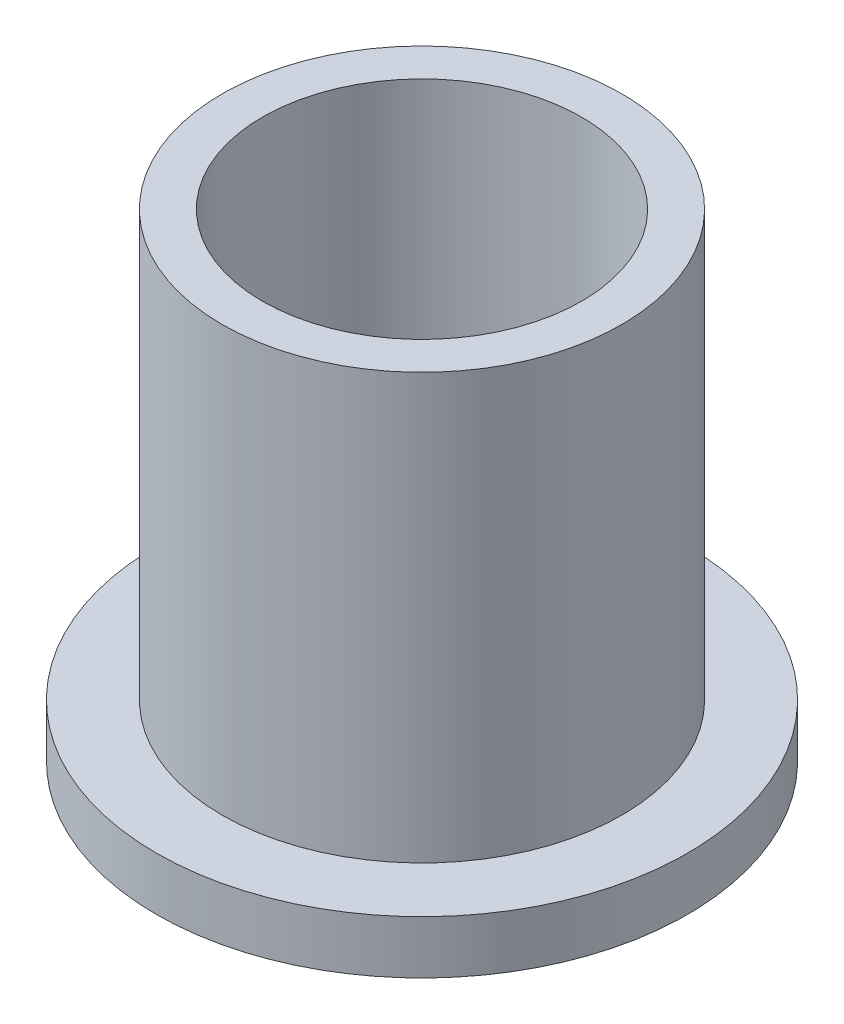
from build123d import *

# Parameters (mm, degrees)
SKETCH2_R           = 11.94435
SKETCH2_R_2         = 9.5377
BOSS_EXTRUDE1_DEPTH = 28.575
SKETCH3_R           = 15.875
SKETCH3_R_2         = 11.94435
BOSS_EXTRUDE2_DEPTH = 3.175


with BuildPart() as part:
    # Sketch2 → Boss-Extrude1 (new body)
    with BuildSketch(Plane(origin=(0, 0, 0), x_dir=(1, 0, 0), z_dir=(0, 1, 0))):
        Circle(SKETCH2_R)
        Circle(SKETCH2_R_2, mode=Mode.SUBTRACT)
    extrude(amount=BOSS_EXTRUDE1_DEPTH)

    # Sketch3 → Boss-Extrude2 (add)
    with BuildSketch(Plane(origin=(0, 0, 0), x_dir=(1, 0, 0), z_dir=(0, 1, 0))):
        Circle(SKETCH3_R)
        Circle(SKETCH3_R_2, mode=Mode.SUBTRACT)
    extrude(amount=BOSS_EXTRUDE2_DEPTH)


solid = part.part
